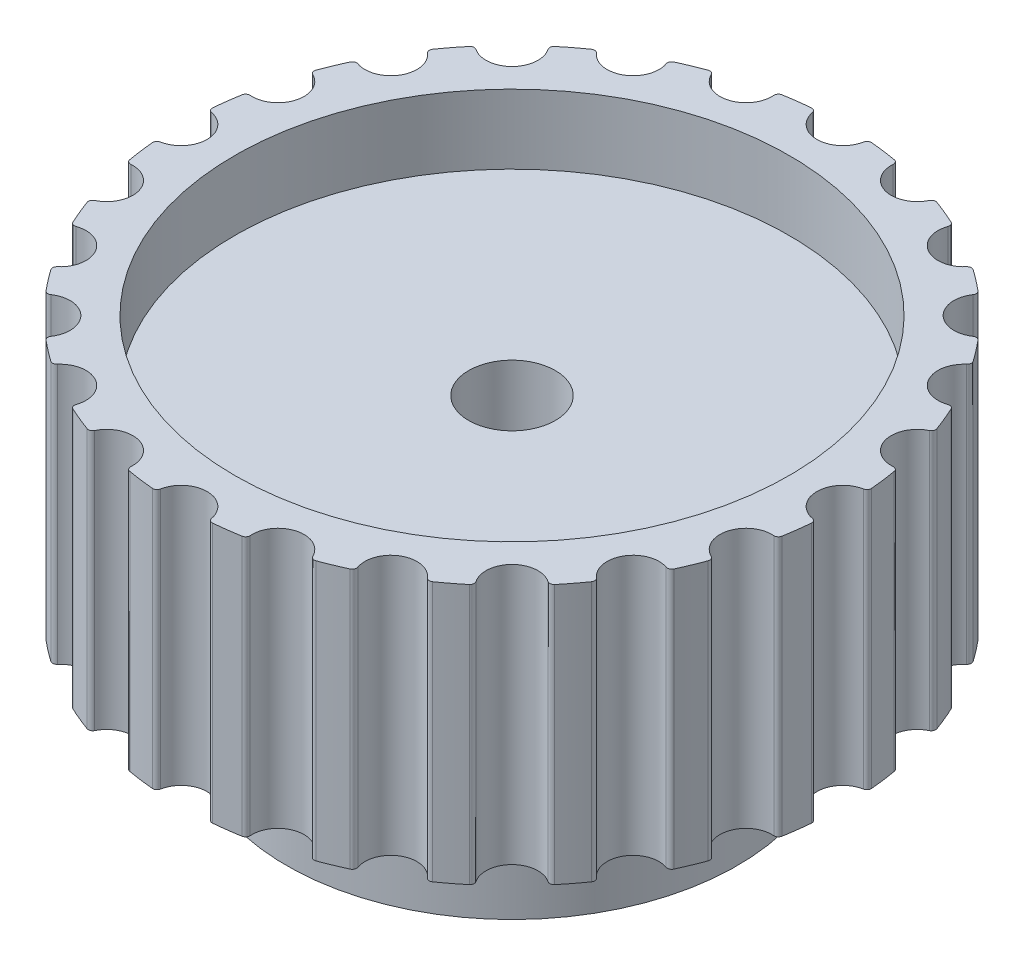
from build123d import *

# Parameters (mm, degrees)
SKETCH1_R           = 19.095
BOSS_EXTRUDE1_DEPTH = 15
SKETCH2_R           = 16
CUT_EXTRUDE1_DEPTH  = 4
SKETCH4_R           = 1.5
CUT_EXTRUDE2_DEPTH  = 16
CIRPATTERN1_COUNT   = 24
FILLET1_R           = 0.25
SKETCH5_R           = 13
BOSS_EXTRUDE2_DEPTH = 10
SKETCH7_R           = 2.5
CUT_EXTRUDE4_DEPTH  = 22.0000001


with BuildPart() as part:
    # Sketch1 → Boss-Extrude1 (new body)
    with BuildSketch(Plane(origin=(0, 0, 0), x_dir=(1, 0, 0), z_dir=(0, 1, 0))):
        Circle(SKETCH1_R)
    extrude(amount=BOSS_EXTRUDE1_DEPTH)

    # Sketch2 → Cut-Extrude1 (cut)
    with BuildSketch(Plane(origin=(0, 15, 0), x_dir=(1, 0, 0), z_dir=(0, 1, 0))):
        Circle(SKETCH2_R)
    cut_extrude1 = extrude(amount=-CUT_EXTRUDE1_DEPTH, mode=Mode.SUBTRACT)

    # Mirror1: Cut-Extrude1 across plane
    add(cut_extrude1.mirror(Plane.ZX.offset(7.5)), mode=Mode.SUBTRACT)

    # Sketch4 → Cut-Extrude2 (cut, through all)
    with BuildSketch(Plane.XZ):
        with Locations((0, 19.095)):
            Circle(SKETCH4_R)
    cut_extrude2 = extrude(amount=-CUT_EXTRUDE2_DEPTH, mode=Mode.SUBTRACT)

    # CirPattern1: Cut-Extrude2 ×24 about axis
    cirpattern1_axis = Axis((0, 0, 0), (0, 1, 0))
    for i in range(1, CIRPATTERN1_COUNT):
        add(cut_extrude2.rotate(cirpattern1_axis, i * 360 / CIRPATTERN1_COUNT), mode=Mode.SUBTRACT)

    # Fillet1
    fillet1_edges = [part.edges().sort_by_distance(p)[0] for p in [
        (-12.400702409, 7.5, -14.520385834),
        (-14.520385834, 7.5, -12.400702409),
        (-8.220006325, 7.5, -17.235153641),
        (-10.816077729, 7.5, -15.736311117),
        (-3.479130394, 7.5, -18.775374209),
        (-6.374671801, 7.5, -17.999516228),
        (1.498842524, 7.5, -19.036084053),
        (-1.498842524, 7.5, -19.036084053),
        (6.374671801, 7.5, -17.999516228),
        (3.479130394, 7.5, -18.775374209),
        (10.816077729, 7.5, -15.736311117),
        (8.220006325, 7.5, -17.235153641),
        (14.520385834, 7.5, -12.400702409),
        (12.400702409, 7.5, -14.520385834),
        (17.235153641, 7.5, -8.220006325),
        (15.736311117, 7.5, -10.816077729),
        (18.775374209, 7.5, -3.479130394),
        (17.999516228, 7.5, -6.374671801),
        (19.036084053, 7.5, 1.498842524),
        (19.036084053, 7.5, -1.498842524),
        (17.999516228, 7.5, 6.374671801),
        (18.775374209, 7.5, 3.479130394),
        (15.736311117, 7.5, 10.816077729),
        (17.235153641, 7.5, 8.220006325),
        (12.400702409, 7.5, 14.520385834),
        (14.520385834, 7.5, 12.400702409),
        (8.220006325, 7.5, 17.235153641),
        (10.816077729, 7.5, 15.736311117),
        (-19.036084053, 7.5, -1.498842524),
        (-19.036084053, 7.5, 1.498842524),
        (-18.775374209, 7.5, 3.479130394),
        (-17.999516228, 7.5, 6.374671801),
        (-1.498842524, 7.5, 19.036084053),
        (-17.235153641, 7.5, 8.220006325),
        (-15.736311117, 7.5, 10.816077729),
        (1.498842524, 7.5, 19.036084053),
        (-14.520385834, 7.5, 12.400702409),
        (-12.400702409, 7.5, 14.520385834),
        (-10.816077729, 7.5, 15.736311117),
        (-8.220006325, 7.5, 17.235153641),
        (-6.374671801, 7.5, 17.999516228),
        (-3.479130394, 7.5, 18.775374209),
        (3.479130394, 7.5, 18.775374209),
        (6.374671801, 7.5, 17.999516228),
        (-17.999516228, 7.5, -6.374671801),
        (-18.775374209, 7.5, -3.479130394),
        (-15.736311117, 7.5, -10.816077729),
        (-17.235153641, 7.5, -8.220006325),
    ]]
    fillet(fillet1_edges, radius=FILLET1_R)

    # Sketch5 → Boss-Extrude2 (add)
    with BuildSketch(Plane.XZ.offset(-4)):
        Circle(SKETCH5_R)
    extrude(amount=BOSS_EXTRUDE2_DEPTH)

    # Sketch7 → Cut-Extrude4 (cut, through all)
    with BuildSketch(Plane.XZ.offset(6)):
        Circle(SKETCH7_R)
    extrude(amount=-CUT_EXTRUDE4_DEPTH, mode=Mode.SUBTRACT)


solid = part.part
